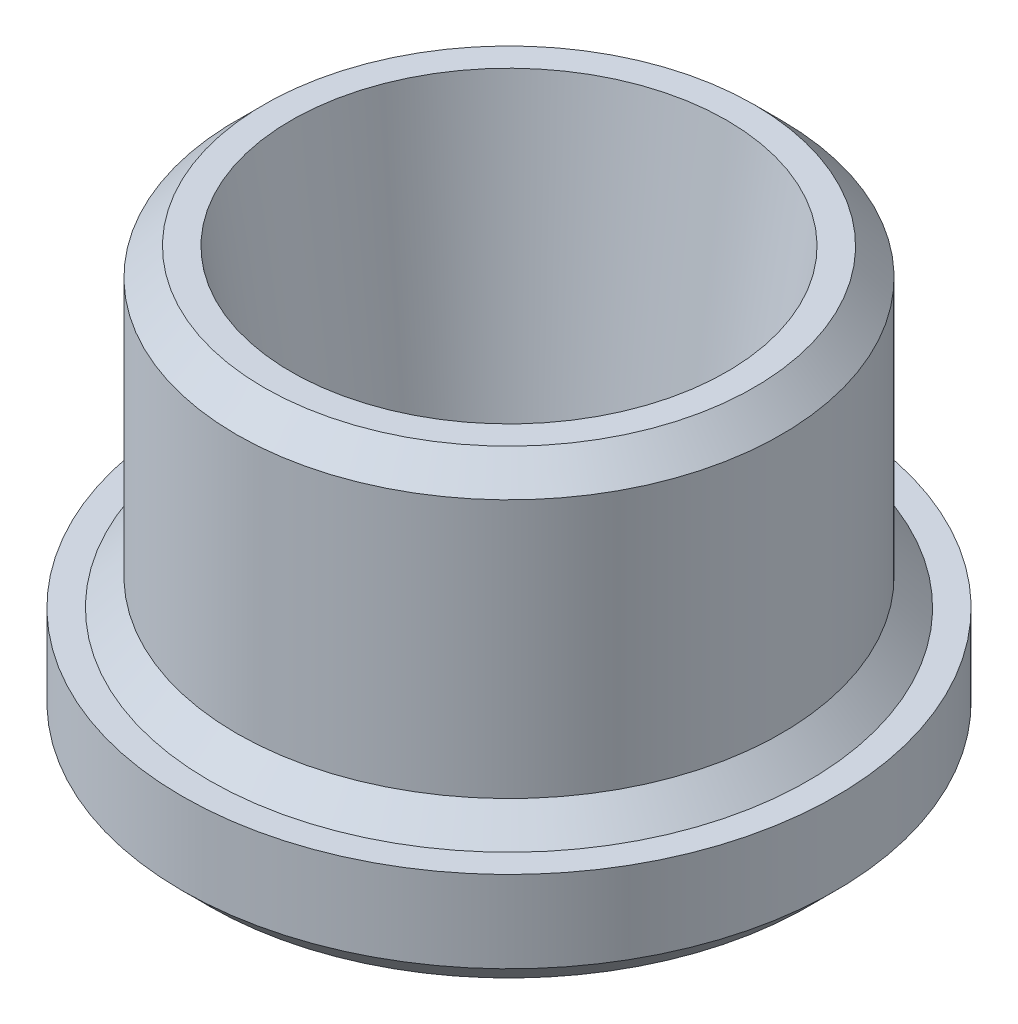
from build123d import *

# Parameters (mm, degrees)
CHANFREIN1_SIZE = 0.5
CHANFREIN2_SIZE = 0.5


with BuildPart() as part:
    # Sketch1 → Revolve1 (revolve)
    with BuildSketch(Plane.XY):
        Polygon((3.15, 0), (6, 0), (6, 2), (5.5, 2), (5, 2.5), (5, 7.75), (4, 7.75), (3.15, 1.75), align=None)
    revolve(axis=Axis((0, -36.960268038, 0), (0, 1, 0)))

    # Chanfrein1
    chanfrein1_edges = [part.edges().sort_by_distance(p)[0] for p in [
        (-6, 0, 0),
    ]]
    chamfer(chanfrein1_edges, length=CHANFREIN1_SIZE)

    # Chanfrein2
    chanfrein2_edges = [part.edges().sort_by_distance(p)[0] for p in [
        (-5, 7.75, 0),
    ]]
    chamfer(chanfrein2_edges, length=CHANFREIN2_SIZE)


solid = part.part
